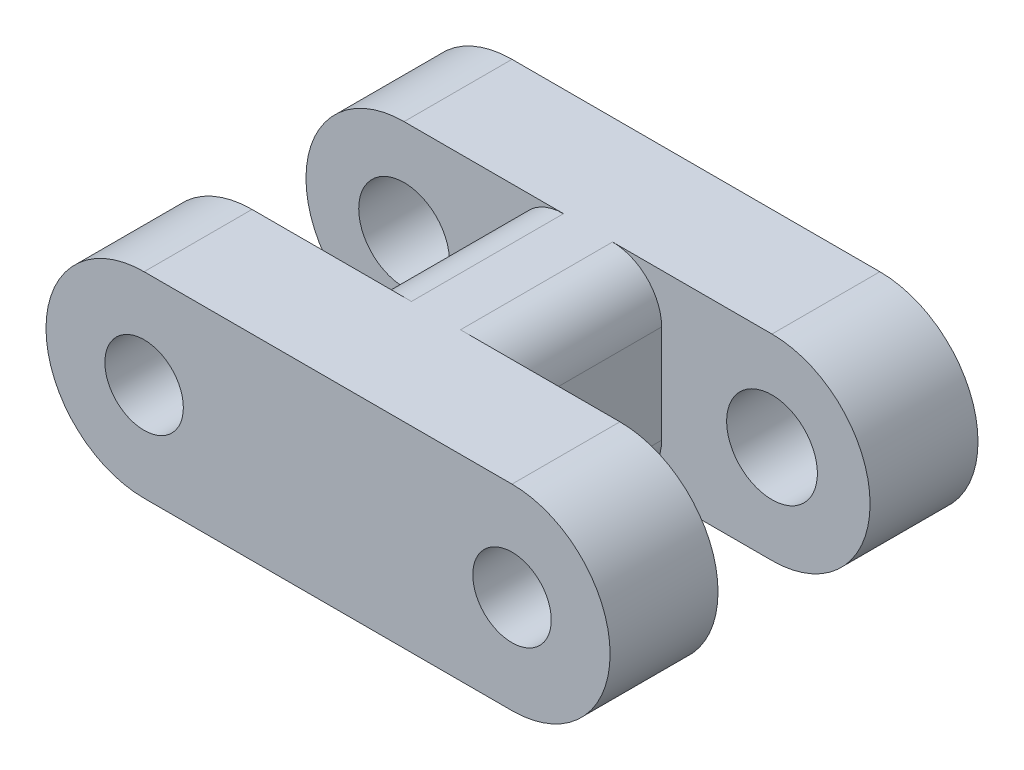
from build123d import *

# Parameters (mm, degrees)
SKETCH1_R               = 1.6
BOSS_EXTRUDE1_DEPTH     = 7.5
CUT_EXTRUDE1_DEPTH      = 21.814658296
CUT_EXTRUDE1_DEPTH_BACK = 21.814658296
SKETCH2_W               = 10
SKETCH2_H               = 6.2
HOLE1_D                 = 3.7
HOLE1_DEPTH             = 4.4
FILLET1_R               = 2


with BuildPart() as part:
    # Sketch1 → Boss-Extrude1 (new, symmetric)
    with BuildSketch(Plane.XY):
        with BuildLine():
            Line((-15, 4), (0, 4))
            ThreePointArc((0, 4), (4, 0), (0, -4))
            Line((0, -4), (-15, -4))
            ThreePointArc((-15, -4), (-19, 0), (-15, 4))
        make_face()
        Circle(SKETCH1_R, mode=Mode.SUBTRACT)
        with Locations((-15, 0)):
            Circle(SKETCH1_R, mode=Mode.SUBTRACT)
    extrude(amount=BOSS_EXTRUDE1_DEPTH, both=True)

    # Sketch2 → Cut-Extrude1 (cut, two sides: drawn at the far end of the back side and taken through both)
    with BuildSketch(Plane(origin=(0, 0, 0), x_dir=(1, 0, 0), z_dir=(0, 1, 0)).offset(-CUT_EXTRUDE1_DEPTH_BACK)):
        with Locations((0.5, 0)):
            Rectangle(SKETCH2_W, SKETCH2_H)
        with Locations((-15.5, 0)):
            Rectangle(SKETCH2_W, SKETCH2_H)
    extrude(amount=CUT_EXTRUDE1_DEPTH + CUT_EXTRUDE1_DEPTH_BACK, mode=Mode.SUBTRACT)

    # Hole1
    with Locations(Plane(origin=(0, 0, -7.5), x_dir=(-1, 0, 0), z_dir=(0, 0, -1))):
        with Locations((0, 0), (15, 0)):
            Hole(HOLE1_D / 2, depth=HOLE1_DEPTH)

    # Fillet1
    fillet1_edges = [part.edges().sort_by_distance(p)[0] for p in [
        (-4.5, -4, 0),
        (-10.5, -4, 0),
        (-4.5, 4, 0),
        (-10.5, 4, 0),
    ]]
    fillet(fillet1_edges, radius=FILLET1_R)


solid = part.part
